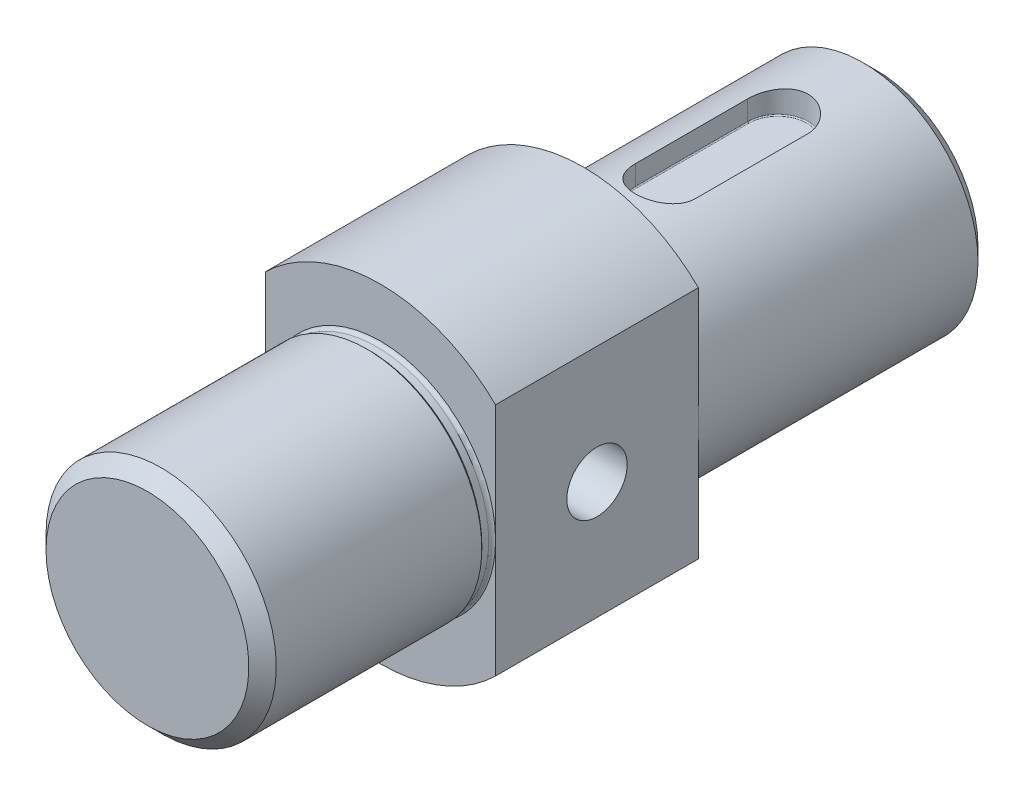
from build123d import *

# Parameters (mm, degrees)
CUT_EXTRUDE_1_DEPTH = 9
FILLET_1_R          = 0.4
CHAMFER_1_SIZE      = 5
CHAMFER_2_SIZE      = 5
SKETCH_5_W          = 18
SKETCH_5_H          = 74
CUT_EXTRUDE_2_DEPTH = 120
SKETCH_6_R          = 11
CUT_EXTRUDE_3_DEPTH = 54.05


with BuildPart() as part:
    # Эскиз1 → Повернуть1 (revolve)
    with BuildSketch(Plane(origin=(0, 0, 0), x_dir=(0, 0, -1), z_dir=(1, 0, 0))):
        Polygon((144, 0), (-122, 0), (-122, 42), (-37, 42), (-37, 60), (37, 60), (37, 42), (144, 42), align=None)
    revolve(axis=Axis((0, 0, 0), (0, 0, 1)))

    # Эскиз2 → Вырез-Вытянуть1 (cut)
    with BuildSketch(Plane(origin=(0, 42, 0), x_dir=(1, 0, 0), z_dir=(0, 1, 0))):
        with BuildLine():
            Line((-11, 67), (-11, 108))
            ThreePointArc((-11, 108), (0, 119), (11, 108))
            Line((11, 108), (11, 67))
            ThreePointArc((11, 67), (0, 56), (-11, 67))
        make_face()
    extrude(amount=-CUT_EXTRUDE_1_DEPTH, mode=Mode.SUBTRACT)

    # Скругление1
    fillet_1_edges = [part.edges().sort_by_distance(p)[0] for p in [
        (0, 33, -56),
        (-11, 33, -87.5),
        (0, 33, -119),
        (11, 33, -87.5),
    ]]
    fillet(fillet_1_edges, radius=FILLET_1_R)

    # Фаска1
    chamfer_1_edges = [part.edges().sort_by_distance(p)[0] for p in [
        (0, -42, -144),
    ]]
    chamfer(chamfer_1_edges, length=CHAMFER_1_SIZE)

    # Фаска2
    chamfer_2_edges = [part.edges().sort_by_distance(p)[0] for p in [
        (0, -42, 122),
    ]]
    chamfer(chamfer_2_edges, length=CHAMFER_2_SIZE)

    # Эскиз3 → Вырез-Повернуть1 (revolve, cut)
    with BuildSketch(Plane(origin=(0, 0, 0), x_dir=(0, 0, -1), z_dir=(1, 0, 0))):
        with BuildLine():
            Line((-37, 42), (-42, 42))
            Line((-42, 42), (-41, 41))
            Line((-41, 41), (-38.483239697, 41))
            ThreePointArc((-38.483239697, 41), (-37.588812506, 41.273350084), (-37, 42))
        make_face()
    revolve(axis=Axis((0, 0, 0), (0, 0, 1)), mode=Mode.SUBTRACT)

    # Эскиз5 → Вырез-Вытянуть2 (cut)
    with BuildSketch(Plane(origin=(0, 60, 0), x_dir=(1, 0, 0), z_dir=(0, 1, 0))):
        with Locations((-51, 0)):
            Rectangle(SKETCH_5_W, SKETCH_5_H)
        with Locations((51, 0)):
            Rectangle(SKETCH_5_W, SKETCH_5_H)
    extrude(amount=-CUT_EXTRUDE_2_DEPTH, mode=Mode.SUBTRACT)

    # Эскиз6 → Вырез-Вытянуть3 (cut)
    with BuildSketch(Plane(origin=(42, 0, 0), x_dir=(0, 0, -1), z_dir=(1, 0, 0))):
        Circle(SKETCH_6_R)
    extrude(amount=-CUT_EXTRUDE_3_DEPTH, mode=Mode.SUBTRACT)

    # Эскиз7 → Вырез-Повернуть6 (revolve, cut)
    with BuildSketch(Plane.XY):
        Polygon((-12.05, 11), (-12.05, 0), (-21.280095943, 0), align=None)
    revolve(axis=Axis((-21, 0, 0), (1, 0, 0)), mode=Mode.SUBTRACT)


solid = part.part
